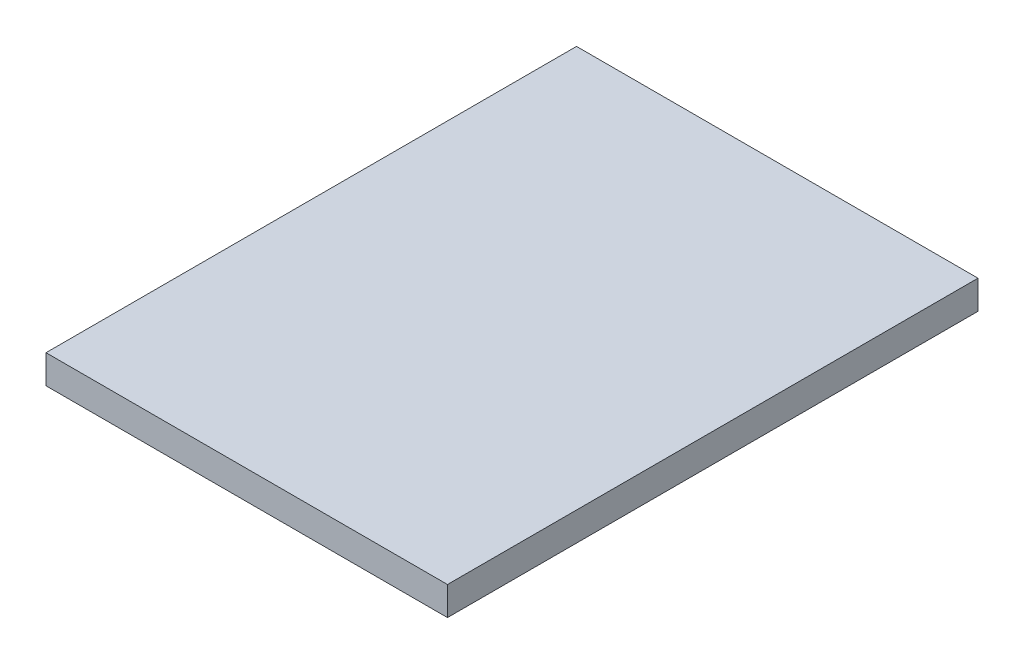
from build123d import *

# Parameters (mm, degrees)
SKETCH1_W           = 224
SKETCH1_H           = 296
BOSS_EXTRUDE1_DEPTH = 16


with BuildPart() as part:
    # Sketch1 → Boss-Extrude1 (new body)
    with BuildSketch(Plane(origin=(0, 0, 0), x_dir=(1, 0, 0), z_dir=(0, 1, 0))):
        Rectangle(SKETCH1_W, SKETCH1_H)
    extrude(amount=BOSS_EXTRUDE1_DEPTH)


solid = part.part
